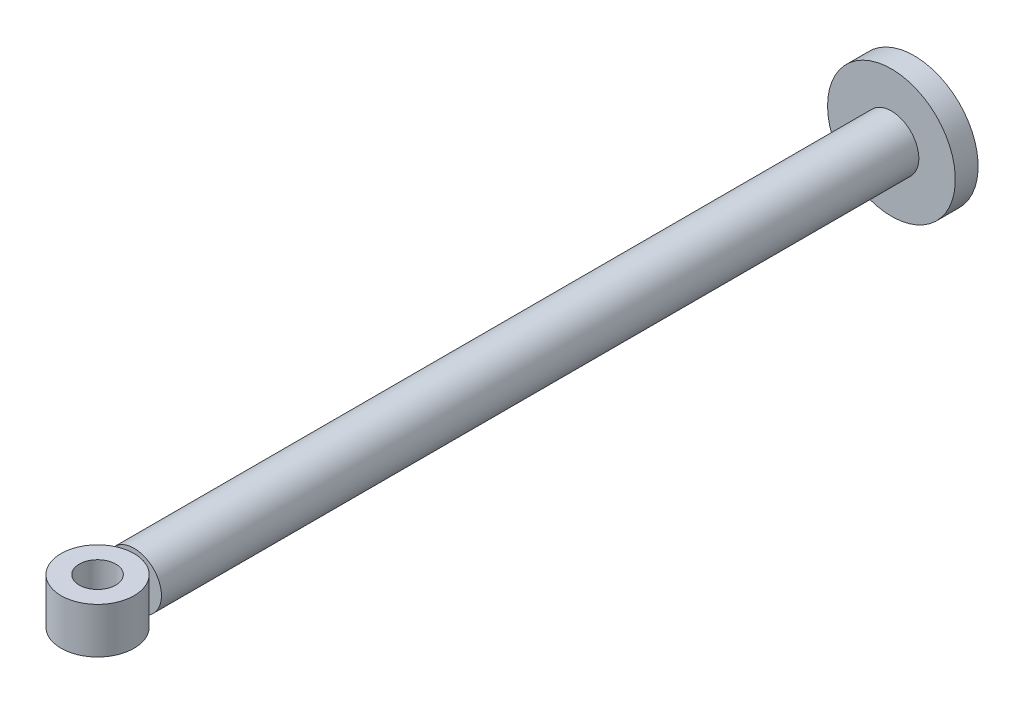
from build123d import *

# Parameters (mm, degrees)
SKETCH1_R                = 3
BOSS_EXTRUDE1_DEPTH      = 85.5
BOSS_EXTRUDE2_DEPTH      = 2.5
BOSS_EXTRUDE2_DEPTH_BACK = 2.5
SKETCH2_R                = 4
SKETCH2_R_2              = 2
SKETCH3_R                = 7
BOSS_EXTRUDE3_DEPTH      = 2.5


with BuildPart() as part:
    # Sketch1 → Boss-Extrude1 (new body)
    with BuildSketch(Plane.XY):
        Circle(SKETCH1_R)
    extrude(amount=BOSS_EXTRUDE1_DEPTH)

    # Sketch3 → Boss-Extrude3 (add)
    with BuildSketch(Plane(origin=(0, 0, 0), x_dir=(-1, 0, 0), z_dir=(0, 0, -1))):
        Circle(SKETCH3_R)
    extrude(amount=-BOSS_EXTRUDE3_DEPTH)


with BuildPart() as body_2:
    # Sketch2 → Boss-Extrude2 (new, two sides: drawn at the far end of the back side and taken through both)
    with BuildSketch(Plane(origin=(0, 0, 0), x_dir=(1, 0, 0), z_dir=(0, 1, 0)).offset(-BOSS_EXTRUDE2_DEPTH_BACK)):
        with Locations((0, -89.5)):
            Circle(SKETCH2_R)
        with Locations((0, -89.5)):
            Circle(SKETCH2_R_2, mode=Mode.SUBTRACT)
    extrude(amount=BOSS_EXTRUDE2_DEPTH + BOSS_EXTRUDE2_DEPTH_BACK)


solid = Compound([part.part, body_2.part])
